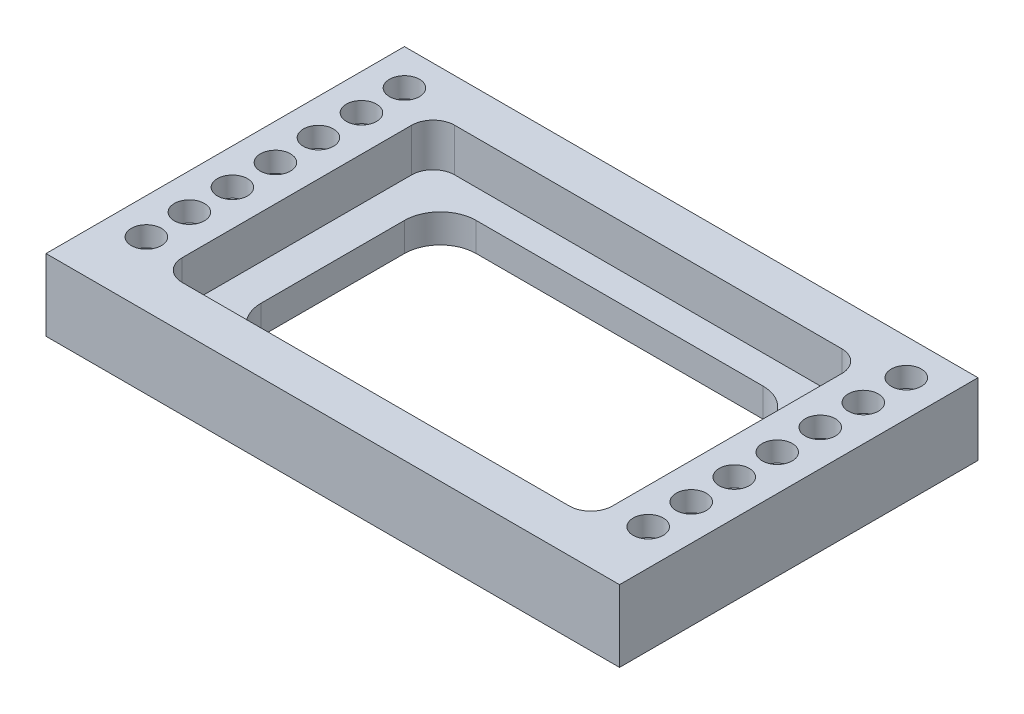
from build123d import *

# Parameters (mm, degrees)
CROQUIS1_W                   = 400
CROQUIS1_H                   = 250
SALIENTE_EXTRUIR1_DEPTH      = 50
CORTAR_EXTRUIR1_DEPTH        = 30
TALADRO1_D                   = 14
TALADRO1_DEPTH               = 49.877349569
TALADRO1_CBORE_D             = 21
TALADRO1_CBORE_DEPTH         = 14
MATRIZL1_COUNT               = 7
MATRIZL1_PITCH               = 30
SIMETR_A1_COPY_1_D           = 14
SIMETR_A1_COPY_1_DEPTH       = 49.877349569
SIMETR_A1_COPY_1_CBORE_D     = 21
SIMETR_A1_COPY_1_CBORE_DEPTH = 14
SIMETR_A1_COPY_2_D           = 14
SIMETR_A1_COPY_2_DEPTH       = 49.877349569
SIMETR_A1_COPY_2_CBORE_D     = 21
SIMETR_A1_COPY_2_CBORE_DEPTH = 14
SIMETR_A1_COPY_3_D           = 14
SIMETR_A1_COPY_3_DEPTH       = 49.877349569
SIMETR_A1_COPY_3_CBORE_D     = 21
SIMETR_A1_COPY_3_CBORE_DEPTH = 14
SIMETR_A1_COPY_4_D           = 14
SIMETR_A1_COPY_4_DEPTH       = 49.877349569
SIMETR_A1_COPY_4_CBORE_D     = 21
SIMETR_A1_COPY_4_CBORE_DEPTH = 14
SIMETR_A1_COPY_5_D           = 14
SIMETR_A1_COPY_5_DEPTH       = 49.877349569
SIMETR_A1_COPY_5_CBORE_D     = 21
SIMETR_A1_COPY_5_CBORE_DEPTH = 14
SIMETR_A1_COPY_6_D           = 14
SIMETR_A1_COPY_6_DEPTH       = 49.877349569
SIMETR_A1_COPY_6_CBORE_D     = 21
SIMETR_A1_COPY_6_CBORE_DEPTH = 14


with BuildPart() as part:
    # Croquis1 → Saliente-Extruir1 (new body)
    with BuildSketch(Plane(origin=(0, 0, 0), x_dir=(1, 0, 0), z_dir=(0, 1, 0))):
        Rectangle(CROQUIS1_W, CROQUIS1_H)
        with BuildLine():
            Line((-100, 75), (100, 75))
            ThreePointArc((100, 75), (117.67766953, 67.67766953), (125, 50))
            Line((125, 50), (125, -50))
            ThreePointArc((125, -50), (117.67766953, -67.67766953), (100, -75))
            Line((100, -75), (-100, -75))
            ThreePointArc((-100, -75), (-117.67766953, -67.67766953), (-125, -50))
            Line((-125, -50), (-125, 50))
            ThreePointArc((-125, 50), (-117.67766953, 67.67766953), (-100, 75))
        make_face(mode=Mode.SUBTRACT)
    extrude(amount=SALIENTE_EXTRUIR1_DEPTH)

    # Croquis2 → Cortar-Extruir1 (cut)
    with BuildSketch(Plane(origin=(0, 50, 0), x_dir=(1, 0, 0), z_dir=(0, 1, 0))):
        with BuildLine():
            Line((-135, 95), (135, 95))
            ThreePointArc((135, 95), (145.606601718, 90.606601718), (150, 80))
            Line((150, 80), (150, -80))
            ThreePointArc((150, -80), (145.606601718, -90.606601718), (135, -95))
            Line((135, -95), (-135, -95))
            ThreePointArc((-135, -95), (-145.606601718, -90.606601718), (-150, -80))
            Line((-150, -80), (-150, 80))
            ThreePointArc((-150, 80), (-145.606601718, 90.606601718), (-135, 95))
        make_face()
    extrude(amount=-CORTAR_EXTRUIR1_DEPTH, mode=Mode.SUBTRACT)

    # Taladro1
    with Locations(Plane(origin=(0, 50, 0), x_dir=(1, 0, 0), z_dir=(0, 1, 0))):
        with Locations((-175, 100)):
            taladro1 = CounterBoreHole(TALADRO1_D / 2, TALADRO1_CBORE_D / 2, TALADRO1_CBORE_DEPTH, depth=TALADRO1_DEPTH)

    # MatrizL1: Taladro1 ×7
    with Locations(*[(0, 0, i * MATRIZL1_PITCH) for i in range(1, MATRIZL1_COUNT)]):
        add(taladro1, mode=Mode.SUBTRACT)

    # Simetría1: Taladro1 across plane
    add(taladro1.mirror(Plane(origin=(0, 0, 0), x_dir=(0, 0, 1), z_dir=(1, 0, 0))), mode=Mode.SUBTRACT)

    # Simetría1 copy 1
    with Locations(Plane(origin=(0, 50, 30), x_dir=(-1, 0, 0), z_dir=(0, 1, 0))):
        with Locations((-175, -100)):
            CounterBoreHole(SIMETR_A1_COPY_1_D / 2, SIMETR_A1_COPY_1_CBORE_D / 2, SIMETR_A1_COPY_1_CBORE_DEPTH, depth=SIMETR_A1_COPY_1_DEPTH)

    # Simetría1 copy 2
    with Locations(Plane(origin=(0, 50, 60), x_dir=(-1, 0, 0), z_dir=(0, 1, 0))):
        with Locations((-175, -100)):
            CounterBoreHole(SIMETR_A1_COPY_2_D / 2, SIMETR_A1_COPY_2_CBORE_D / 2, SIMETR_A1_COPY_2_CBORE_DEPTH, depth=SIMETR_A1_COPY_2_DEPTH)

    # Simetría1 copy 3
    with Locations(Plane(origin=(0, 50, 90), x_dir=(-1, 0, 0), z_dir=(0, 1, 0))):
        with Locations((-175, -100)):
            CounterBoreHole(SIMETR_A1_COPY_3_D / 2, SIMETR_A1_COPY_3_CBORE_D / 2, SIMETR_A1_COPY_3_CBORE_DEPTH, depth=SIMETR_A1_COPY_3_DEPTH)

    # Simetría1 copy 4
    with Locations(Plane(origin=(0, 50, 120), x_dir=(-1, 0, 0), z_dir=(0, 1, 0))):
        with Locations((-175, -100)):
            CounterBoreHole(SIMETR_A1_COPY_4_D / 2, SIMETR_A1_COPY_4_CBORE_D / 2, SIMETR_A1_COPY_4_CBORE_DEPTH, depth=SIMETR_A1_COPY_4_DEPTH)

    # Simetría1 copy 5
    with Locations(Plane(origin=(0, 50, 150), x_dir=(-1, 0, 0), z_dir=(0, 1, 0))):
        with Locations((-175, -100)):
            CounterBoreHole(SIMETR_A1_COPY_5_D / 2, SIMETR_A1_COPY_5_CBORE_D / 2, SIMETR_A1_COPY_5_CBORE_DEPTH, depth=SIMETR_A1_COPY_5_DEPTH)

    # Simetría1 copy 6
    with Locations(Plane(origin=(0, 50, 180), x_dir=(-1, 0, 0), z_dir=(0, 1, 0))):
        with Locations((-175, -100)):
            CounterBoreHole(SIMETR_A1_COPY_6_D / 2, SIMETR_A1_COPY_6_CBORE_D / 2, SIMETR_A1_COPY_6_CBORE_DEPTH, depth=SIMETR_A1_COPY_6_DEPTH)


solid = part.part
